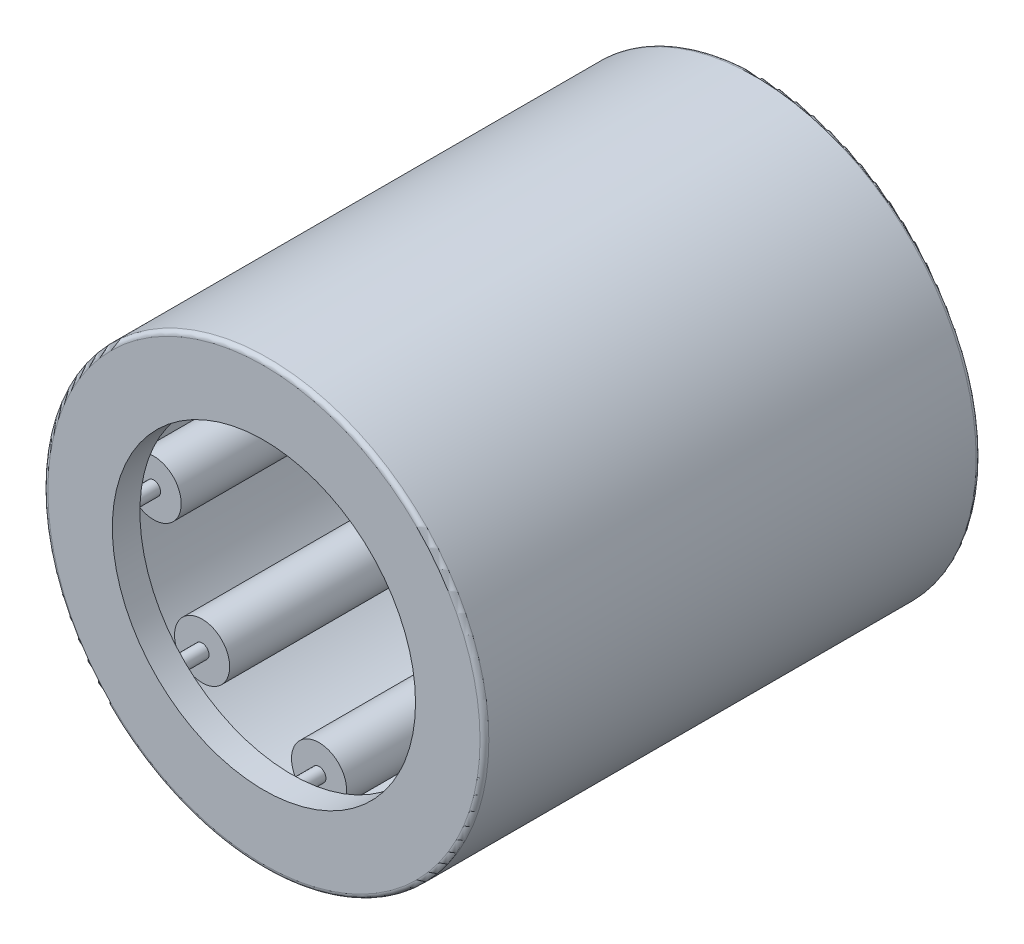
from build123d import *

# Parameters (mm, degrees)
SKETCH2_W         = 11.1125
SKETCH2_H         = 0.5953125
SKETCH3_W         = 12.7
SKETCH3_H         = 0.1984375
CIRPATTERN1_COUNT = 8
CIRPATTERN1_ANGLE = 315
FILLET1_R         = 0.127


with BuildPart() as part:
    # Sketch1 → Revolve1 (revolve)
    with BuildSketch(Plane(origin=(0, 0, 0), x_dir=(0, 0, -1), z_dir=(1, 0, 0))):
        Polygon((-7.14375, 6.35), (7.14375, 6.35), (7.14375, 4.365625), (6.35, 4.365625), (6.35, 5.55625), (-6.35, 5.55625), (-6.35, 4.365625), (-7.14375, 4.365625), align=None)
    revolve(axis=Axis((0, 0, 7.14375), (0, 0, -1)))

    # Fillet1
    fillet1_edges = [part.edges().sort_by_distance(p)[0] for p in [
        (0, -6.35, -7.14375),
        (0, -6.35, 7.14375),
    ]]
    fillet(fillet1_edges, radius=FILLET1_R)


with BuildPart() as body_2:
    # Sketch2 → Revolve2 (revolve)
    with BuildSketch(Plane(origin=(0, 0, 0), x_dir=(0, 0, -1), z_dir=(1, 0, 0))):
        with Locations((0, 5.25859375)):
            Rectangle(SKETCH2_W, SKETCH2_H)
    revolve(axis=Axis((0, 4.7625, 5.55625), (0, 0, -1)))


with BuildPart() as body_3:
    # Sketch3 → Revolve3 (revolve)
    with BuildSketch(Plane(origin=(0, 0, 0), x_dir=(0, 0, -1), z_dir=(1, 0, 0))):
        with Locations((0, 4.86171875)):
            Rectangle(SKETCH3_W, SKETCH3_H)
    revolve(axis=Axis((0, 4.7625, 6.35), (0, 0, -1)))


with BuildPart() as cirpattern1_1:
    # CirPattern1: pattern copy
    add(body_2.part.rotate(Axis((0, 0, -7.14375), (0, 0, 1)), 1 * CIRPATTERN1_ANGLE / (CIRPATTERN1_COUNT - 1)))


with BuildPart() as cirpattern1_2:
    # CirPattern1: pattern copy
    add(body_2.part.rotate(Axis((0, 0, -7.14375), (0, 0, 1)), 2 * CIRPATTERN1_ANGLE / (CIRPATTERN1_COUNT - 1)))


with BuildPart() as cirpattern1_3:
    # CirPattern1: pattern copy
    add(body_2.part.rotate(Axis((0, 0, -7.14375), (0, 0, 1)), 3 * CIRPATTERN1_ANGLE / (CIRPATTERN1_COUNT - 1)))


with BuildPart() as cirpattern1_4:
    # CirPattern1: pattern copy
    add(body_2.part.rotate(Axis((0, 0, -7.14375), (0, 0, 1)), 4 * CIRPATTERN1_ANGLE / (CIRPATTERN1_COUNT - 1)))


with BuildPart() as cirpattern1_5:
    # CirPattern1: pattern copy
    add(body_2.part.rotate(Axis((0, 0, -7.14375), (0, 0, 1)), 5 * CIRPATTERN1_ANGLE / (CIRPATTERN1_COUNT - 1)))


with BuildPart() as cirpattern1_6:
    # CirPattern1: pattern copy
    add(body_2.part.rotate(Axis((0, 0, -7.14375), (0, 0, 1)), 6 * CIRPATTERN1_ANGLE / (CIRPATTERN1_COUNT - 1)))


with BuildPart() as cirpattern1_7:
    # CirPattern1: pattern copy
    add(body_2.part.rotate(Axis((0, 0, -7.14375), (0, 0, 1)), 7 * CIRPATTERN1_ANGLE / (CIRPATTERN1_COUNT - 1)))


with BuildPart() as cirpattern1_8:
    # CirPattern1: pattern copy
    add(body_3.part.rotate(Axis((0, 0, -7.14375), (0, 0, 1)), 1 * CIRPATTERN1_ANGLE / (CIRPATTERN1_COUNT - 1)))


with BuildPart() as cirpattern1_9:
    # CirPattern1: pattern copy
    add(body_3.part.rotate(Axis((0, 0, -7.14375), (0, 0, 1)), 2 * CIRPATTERN1_ANGLE / (CIRPATTERN1_COUNT - 1)))


with BuildPart() as cirpattern1_10:
    # CirPattern1: pattern copy
    add(body_3.part.rotate(Axis((0, 0, -7.14375), (0, 0, 1)), 3 * CIRPATTERN1_ANGLE / (CIRPATTERN1_COUNT - 1)))


with BuildPart() as cirpattern1_11:
    # CirPattern1: pattern copy
    add(body_3.part.rotate(Axis((0, 0, -7.14375), (0, 0, 1)), 4 * CIRPATTERN1_ANGLE / (CIRPATTERN1_COUNT - 1)))


with BuildPart() as cirpattern1_12:
    # CirPattern1: pattern copy
    add(body_3.part.rotate(Axis((0, 0, -7.14375), (0, 0, 1)), 5 * CIRPATTERN1_ANGLE / (CIRPATTERN1_COUNT - 1)))


with BuildPart() as cirpattern1_13:
    # CirPattern1: pattern copy
    add(body_3.part.rotate(Axis((0, 0, -7.14375), (0, 0, 1)), 6 * CIRPATTERN1_ANGLE / (CIRPATTERN1_COUNT - 1)))


with BuildPart() as cirpattern1_14:
    # CirPattern1: pattern copy
    add(body_3.part.rotate(Axis((0, 0, -7.14375), (0, 0, 1)), 7 * CIRPATTERN1_ANGLE / (CIRPATTERN1_COUNT - 1)))


solid = Compound([part.part, body_2.part, body_3.part, cirpattern1_1.part, cirpattern1_2.part, cirpattern1_3.part, cirpattern1_4.part, cirpattern1_5.part, cirpattern1_6.part, cirpattern1_7.part, cirpattern1_8.part, cirpattern1_9.part, cirpattern1_10.part, cirpattern1_11.part, cirpattern1_12.part, cirpattern1_13.part, cirpattern1_14.part])
